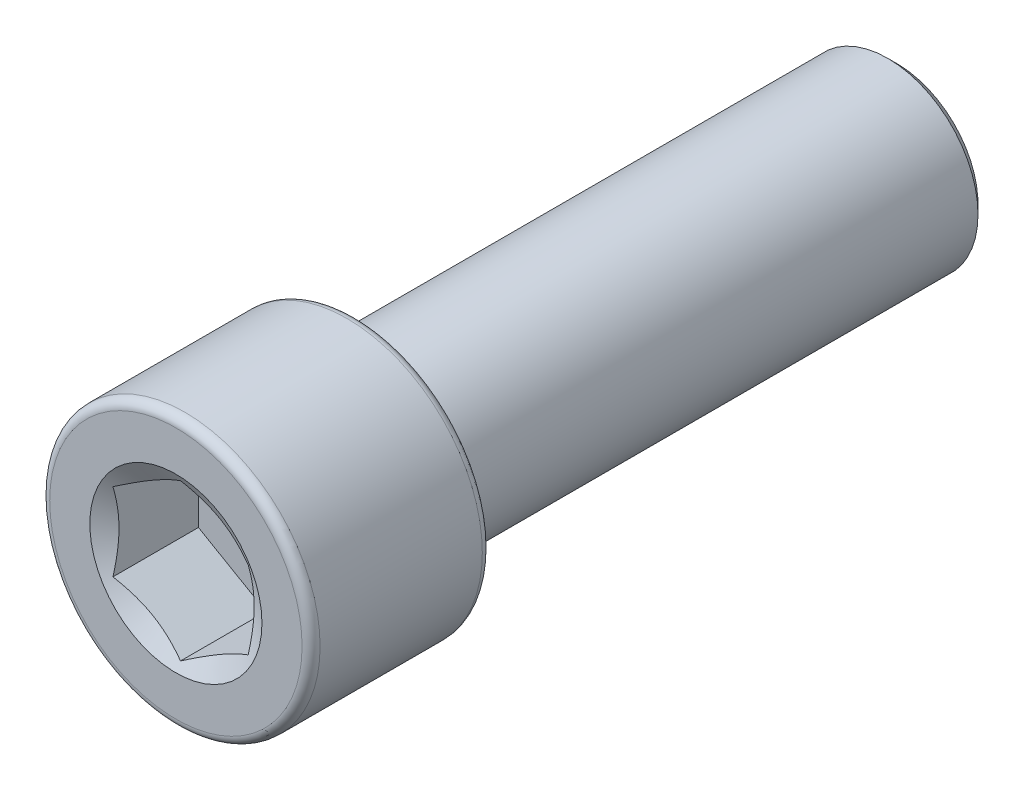
from build123d import *

# Parameters (mm, degrees)
CUT_EXTRUDE1_START = 12.7
CUT_EXTRUDE1_DEPTH = 3.175


with BuildPart() as part:
    # Sketch2 → Revolve1 (revolve)
    with BuildSketch(Plane(origin=(0, 0, 0), x_dir=(0, 0, -1), z_dir=(1, 0, 0)), mode=Mode.PRIVATE) as revolve1_sk:
        with BuildLine():
            Line((12.7, 0), (12.7, 2.8575))
            Line((12.7, 2.8575), (12.3825, 3.175))
            Line((12.3825, 3.175), (-6.35, 3.175))
            Line((-6.35, 3.175), (-6.35, 4.445))
            ThreePointArc((-6.35, 4.445), (-6.442993597, 4.669506403), (-6.6675, 4.7625))
            Line((-6.6675, 4.7625), (-12.3825, 4.7625))
            ThreePointArc((-12.3825, 4.7625), (-12.607006403, 4.669506403), (-12.7, 4.445))
            Line((-12.7, 4.445), (-12.7, 0))
            Line((-12.7, 0), (12.7, 0))
        make_face()
    revolve(revolve1_sk.sketch.rotate(Axis((0, 0, -12.7), (0, 0, 1)), 90), axis=Axis((0, 0, -12.7), (0, 0, 1)))

    # Sketch3 → Cut-Extrude1 (cut)
    with BuildSketch(Plane.XY.offset(CUT_EXTRUDE1_START)):
        Polygon((-2.38125, 1.374815329), (-2.38125, -1.374815329), (0, -2.749630657), (2.38125, -1.374815329), (2.38125, 1.374815329), (0, 2.749630657), align=None)
    extrude(amount=-CUT_EXTRUDE1_DEPTH, mode=Mode.SUBTRACT)

    # Cut-Extrude2 cone 1 section (through the dimple's axis) → Cut-Extrude2 (revolve, cut)
    with BuildSketch(Plane(origin=(0, 0, 12.7), x_dir=(0, -1, 0), z_dir=(1, 0, 0))):
        Polygon((0, 0), (3.032192214, 0), (0, 1.750636991), align=None)
    revolve(axis=Axis((0, 0, 12.7), (0, 0, -1)), mode=Mode.SUBTRACT)


solid = part.part
